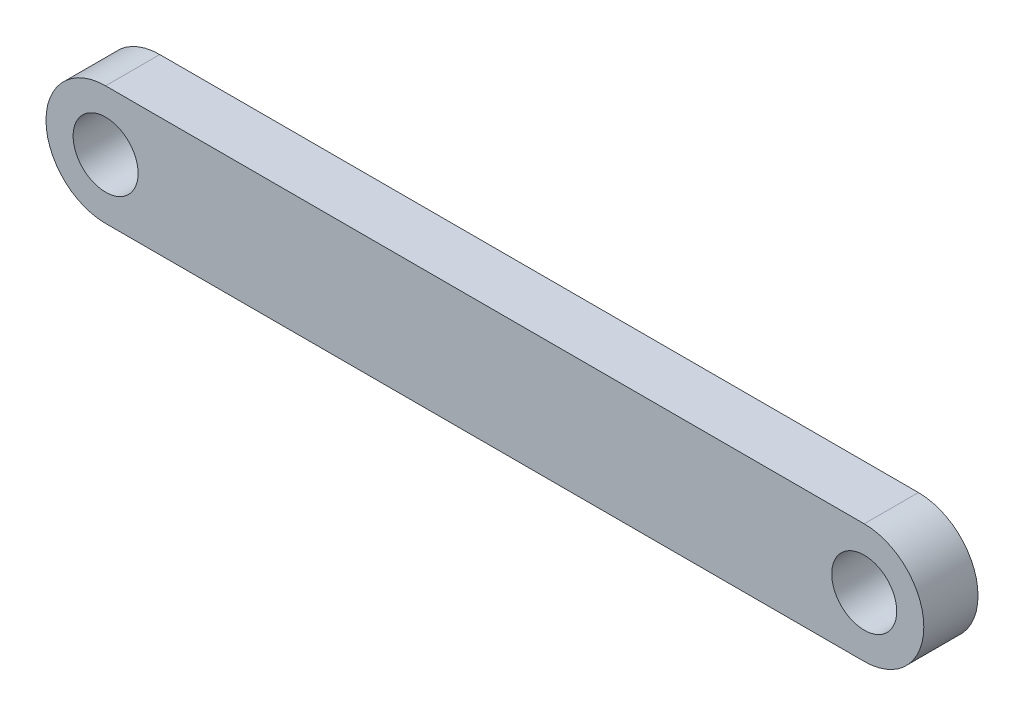
from build123d import *

# Parameters (mm, degrees)
SKETCH1_R           = 3
BOSS_EXTRUDE1_DEPTH = 2.5


with BuildPart() as part:
    # Sketch1 → Boss-Extrude1 (new body, symmetric)
    with BuildSketch(Plane.XY):
        with BuildLine():
            Line((35, -5.5), (-35, -5.5))
            ThreePointArc((-35, -5.5), (-40.5, 0), (-35, 5.5))
            Line((-35, 5.5), (35, 5.5))
            ThreePointArc((35, 5.5), (40.5, 0), (35, -5.5))
        make_face()
        with Locations((35, 0)):
            Circle(SKETCH1_R, mode=Mode.SUBTRACT)
        with Locations((-35, 0)):
            Circle(SKETCH1_R, mode=Mode.SUBTRACT)
    extrude(amount=BOSS_EXTRUDE1_DEPTH, both=True)


solid = part.part
